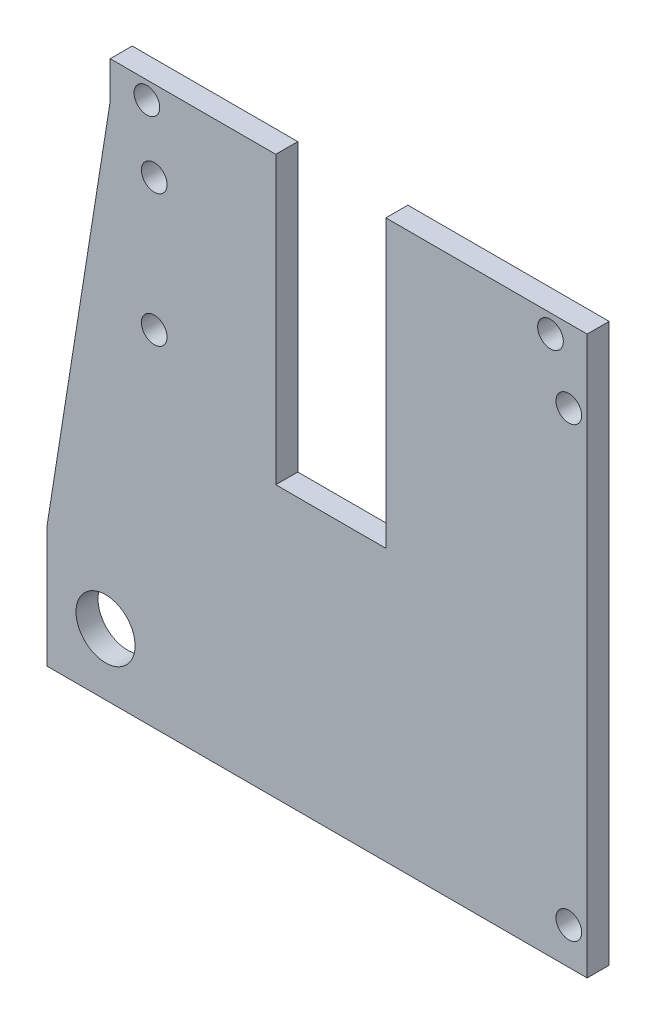
from build123d import *

# Parameters (mm, degrees)
EXTRUDE_START   = -16
SKETCH_1_R      = 1.75
SKETCH_1_R_2    = 4.025
EXTRUDE_1_DEPTH = 3


with BuildPart() as part:
    # ｽｹｯﾁ1 → ﾎﾞｽ - 押し出し1 (new body)
    with BuildSketch(Plane.XY.offset(EXTRUDE_START)):
        Polygon((8.636200269, 92.596668368), (0, 38), (0, 21.596668368), (68.636200269, 21.596668368), (73.636200269, 21.596668368), (73.636200269, 97.596668368), (60, 97.596668368), (46.2, 97.596668368), (46.2, 92.596668368), (46.2, 58.596668368), (31.2, 58.596668368), (31.2, 92.596668368), (31.2, 97.596668368), (8.636200269, 97.596668368), align=None)
        with Locations((14.636200269, 86.596668368)):
            Circle(SKETCH_1_R, mode=Mode.SUBTRACT)
        with Locations((14.636200269, 68.596668368)):
            Circle(SKETCH_1_R, mode=Mode.SUBTRACT)
        with Locations((8, 30)):
            Circle(SKETCH_1_R_2, mode=Mode.SUBTRACT)
        with Locations((71.136200269, 26.596668368)):
            Circle(SKETCH_1_R, mode=Mode.SUBTRACT)
        with Locations((71.136200269, 87.596668368)):
            Circle(SKETCH_1_R, mode=Mode.SUBTRACT)
        with Locations((68.636200269, 95.096668368)):
            Circle(SKETCH_1_R, mode=Mode.SUBTRACT)
        with Locations((13.636200269, 95.202370808)):
            Circle(SKETCH_1_R, mode=Mode.SUBTRACT)
    extrude(amount=-EXTRUDE_1_DEPTH)


solid = part.part
